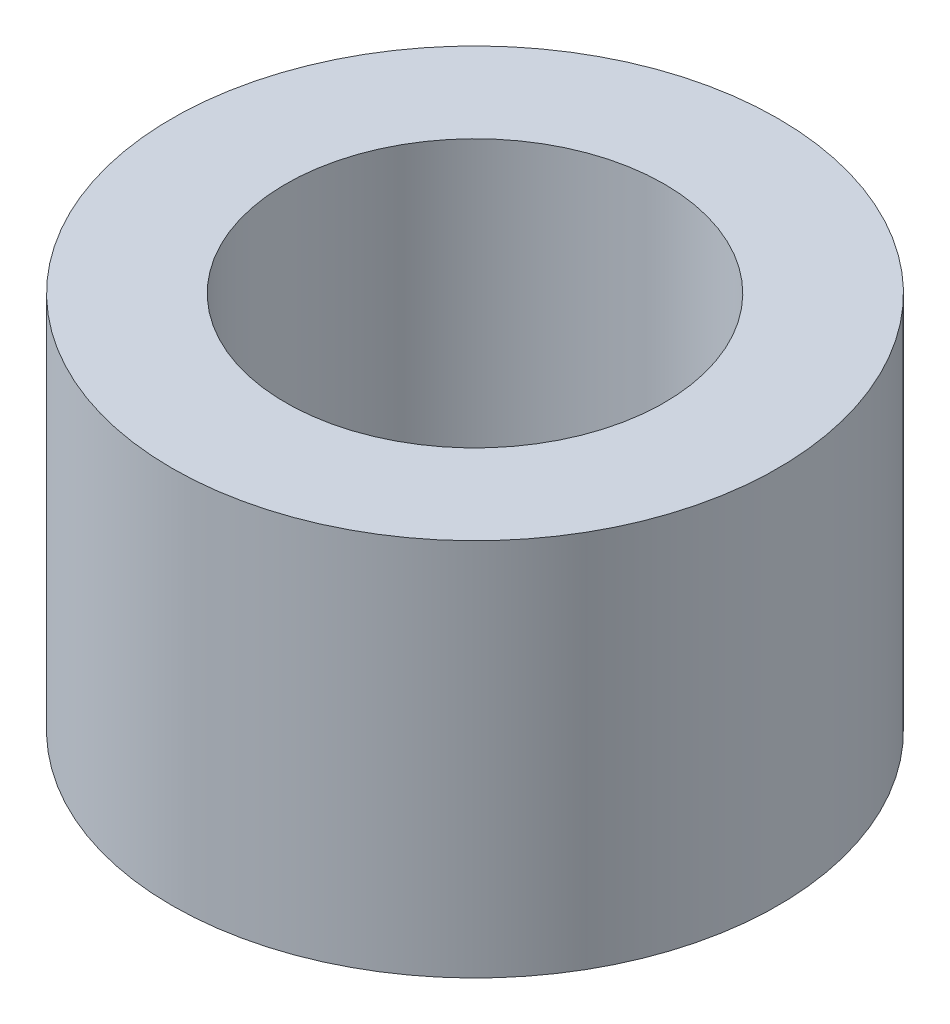
from build123d import *

# Parameters (mm, degrees)
SKETCH1_R           = 5.08
BOSS_EXTRUDE1_DEPTH = 6.35
SKETCH2_R           = 3.175
CUT_EXTRUDE1_DEPTH  = 7.35


with BuildPart() as part:
    # Sketch1 → Boss-Extrude1 (new body)
    with BuildSketch(Plane(origin=(0, 0, 0), x_dir=(1, 0, 0), z_dir=(0, 1, 0))):
        Circle(SKETCH1_R)
    extrude(amount=BOSS_EXTRUDE1_DEPTH)

    # Sketch2 → Cut-Extrude1 (cut, through all)
    with BuildSketch(Plane.XZ):
        Circle(SKETCH2_R)
    extrude(amount=-CUT_EXTRUDE1_DEPTH, mode=Mode.SUBTRACT)


solid = part.part
